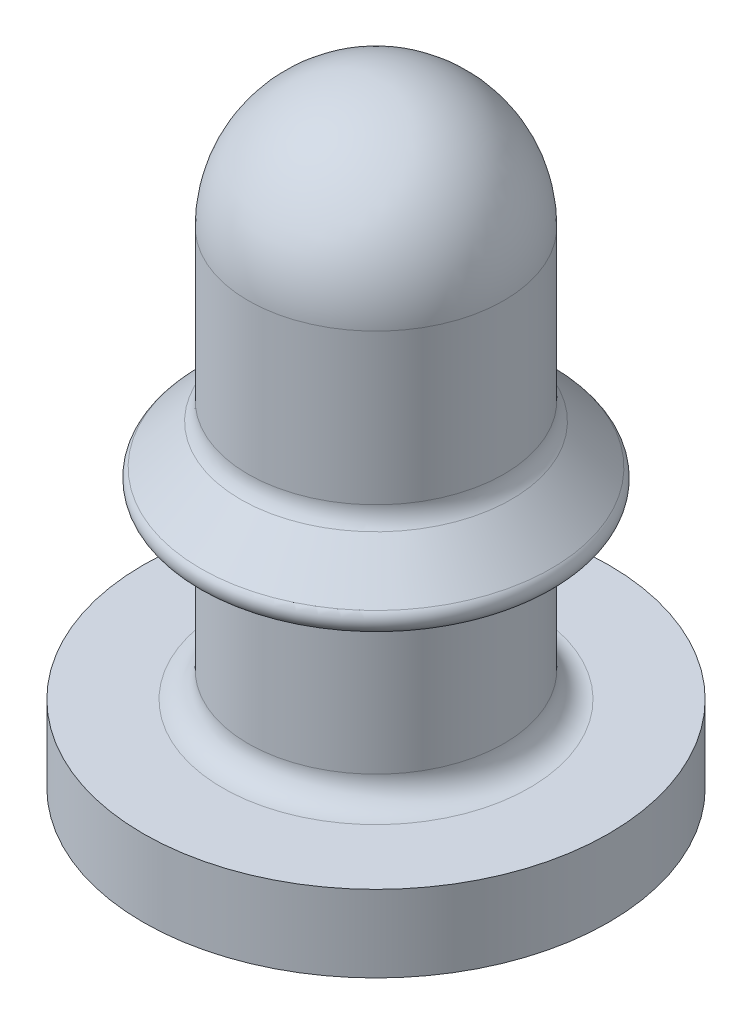
from build123d import *

# Parameters (mm, degrees)
SKETCH1_R           = 2.5
BOSS_EXTRUDE1_DEPTH = 12
SKETCH6_R           = 4.55
BOSS_EXTRUDE3_DEPTH = 1.5
SKETCH2_R           = 1
CUT_EXTRUDE1_DEPTH  = 10
DRAFT1_ANGLE        = 1
BOSS_EXTRUDE2_DEPTH = 10
FILLET1_R           = 0.5


with BuildPart() as part:
    # Sketch1 → Boss-Extrude1 (new body)
    with BuildSketch(Plane(origin=(0, 0, 0), x_dir=(1, 0, 0), z_dir=(0, 1, 0))):
        Circle(SKETCH1_R)
    extrude(amount=BOSS_EXTRUDE1_DEPTH)

    # Sketch6 → Boss-Extrude3 (add)
    with BuildSketch(Plane.XZ):
        Circle(SKETCH6_R)
    extrude(amount=-BOSS_EXTRUDE3_DEPTH)

    # Sketch8 → Revolve1 (revolve)
    with BuildSketch(Plane.XY):
        with BuildLine():
            Line((2.5, 6.353553391), (3.426776695, 5.426776695))
            ThreePointArc((3.426776695, 5.426776695), (3.480969883, 5.154329142), (3.25, 5))
            Line((3.25, 5), (2.5, 5))
            Line((2.5, 5), (2.5, 6.353553391))
        make_face()
    revolve(axis=Axis((0, 0, 0), (0, 1, 0)))

    # Sketch2 → Cut-Extrude1 (cut)
    with BuildSketch(Plane.XZ):
        Circle(SKETCH2_R)
    extrude(amount=-CUT_EXTRUDE1_DEPTH, mode=Mode.SUBTRACT)

    # Draft1
    draft1_faces = [part.faces().sort_by_distance(p)[0] for p in [
        (-1, 5, 0),
    ]]
    draft(draft1_faces, Plane(origin=(0, 10, 0), x_dir=(0, 0, -1), z_dir=(0, -1, 0)), DRAFT1_ANGLE)

    # Sketch7 → Cut-Revolve3 (revolve, cut)
    with BuildSketch(Plane.XY):
        with BuildLine():
            Line((2.5, 9.5), (3.080651327, 9.5))
            Line((3.080651327, 9.5), (3.080651327, 12.580651327))
            Line((3.080651327, 12.580651327), (0, 12.580651327))
            Line((0, 12.580651327), (0, 12))
            ThreePointArc((0, 12), (1.767766953, 11.267766953), (2.5, 9.5))
        make_face()
    revolve(axis=Axis((0, 9.5, 0), (0, 1, 0)), mode=Mode.SUBTRACT)

    # Sketch3 → Boss-Extrude2 (add)
    with BuildSketch(Plane.XZ.offset(-10)):
        with BuildLine():
            Line((1.151036246, 0.233847786), (0.746, 0))
            Line((0.746, 0), (1.151036246, -0.233847786))
            ThreePointArc((1.151036246, -0.233847786), (1.174550649, 0), (1.151036246, 0.233847786))
        make_face()
        with BuildLine():
            Line((-0.373, -1.113750523), (-0.373, -0.646054951))
            Line((-0.373, -0.646054951), (-0.778036246, -0.879902737))
            ThreePointArc((-0.778036246, -0.879902737), (-0.587275325, -1.0171907), (-0.373, -1.113750523))
        make_face()
        with BuildLine():
            Line((-0.778036246, 0.879902737), (-0.373, 0.646054951))
            Line((-0.373, 0.646054951), (-0.373, 1.113750523))
            ThreePointArc((-0.373, 1.113750523), (-0.587275325, 1.0171907), (-0.778036246, 0.879902737))
        make_face()
    extrude(amount=BOSS_EXTRUDE2_DEPTH)

    # Sketch4 → Cut-Revolve1 (revolve, cut)
    with BuildSketch(Plane.XY):
        Polygon((1.174550649, 0), (0.746, 0.510726776), (0, 0.510726776), (0, 0), align=None)
    revolve(axis=Axis((0, 0.510726776, 0), (0, -1, 0)), mode=Mode.SUBTRACT)

    # Fillet1
    fillet1_edges = [part.edges().sort_by_distance(p)[0] for p in [
        (-2.5, 5, 0),
        (-2.5, 6.353553391, 0),
        (-2.5, 1.5, 0),
    ]]
    fillet(fillet1_edges, radius=FILLET1_R)


solid = part.part
